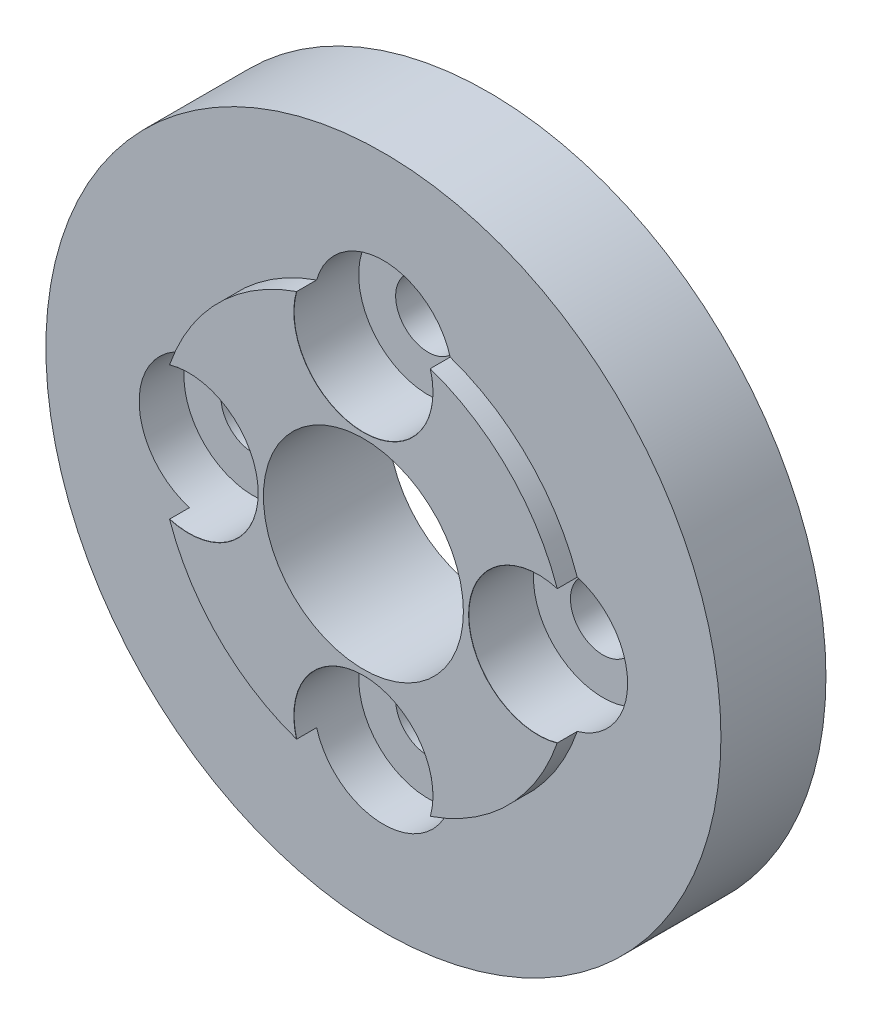
from build123d import *

# Parameters (mm, degrees)
CROQUIS1_R              = 67.5
CROQUIS1_R_2            = 20
SALIENTE_EXTRUIR1_DEPTH = 21
CROQUIS2_R              = 41
CROQUIS2_R_2            = 20
SALIENTE_EXTRUIR2_DEPTH = 4
MATRIZC1_COUNT          = 4


with BuildPart() as part:
    # Croquis1 → Saliente-Extruir1 (new body)
    with BuildSketch(Plane.XY):
        Circle(CROQUIS1_R)
        Circle(CROQUIS1_R_2, mode=Mode.SUBTRACT)
    extrude(amount=SALIENTE_EXTRUIR1_DEPTH)

    # Croquis2 → Saliente-Extruir2 (add)
    with BuildSketch(Plane.XY.offset(21)):
        Circle(CROQUIS2_R)
        Circle(CROQUIS2_R_2, mode=Mode.SUBTRACT)
    extrude(amount=SALIENTE_EXTRUIR2_DEPTH)

    # Croquis7 → Refrentado para perno con cabeza hexagonal de M122 (revolve, cut)
    with BuildSketch(Plane(origin=(0, 34.95, 25), x_dir=(0, -1, 0), z_dir=(1, 0, 0))):
        Polygon((0, 0), (0, 25), (6.5, 25), (6.5, 12.95), (13.89, 12.95), (13.89, 0.025), (13.915, 0), align=None)
    refrentado_para_perno_con_cabeza_hexagon = revolve(axis=Axis((0, 34.95, 31.35), (0, 0, -1)), mode=Mode.SUBTRACT)

    # MatrizC1: Refrentado para perno con cabeza hexagonal de M122 ×4 about axis
    matrizc1_axis = Axis((0, 0, 0), (0, 0, 1))
    for i in range(1, MATRIZC1_COUNT):
        add(refrentado_para_perno_con_cabeza_hexagon.rotate(matrizc1_axis, i * 360 / MATRIZC1_COUNT), mode=Mode.SUBTRACT)


solid = part.part
